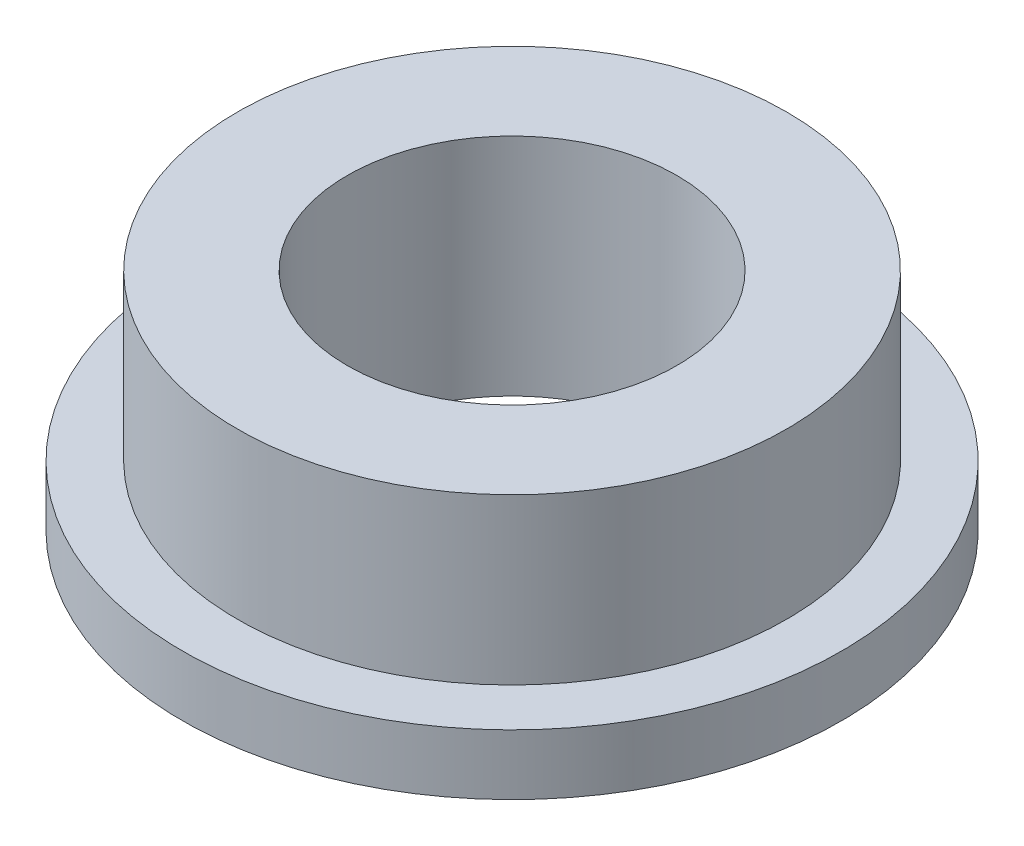
from build123d import *


with BuildPart() as part:
    # Sketch1 → Revolve1 (revolve)
    with BuildSketch(Plane.XY):
        Polygon((-6, 0), (-3, 0), (-3, 4.1), (-5, 4.1), (-5, 1.1), (-6, 1.1), align=None)
    revolve(axis=Axis((0, 0, 0), (0, 1, 0)))


solid = part.part
